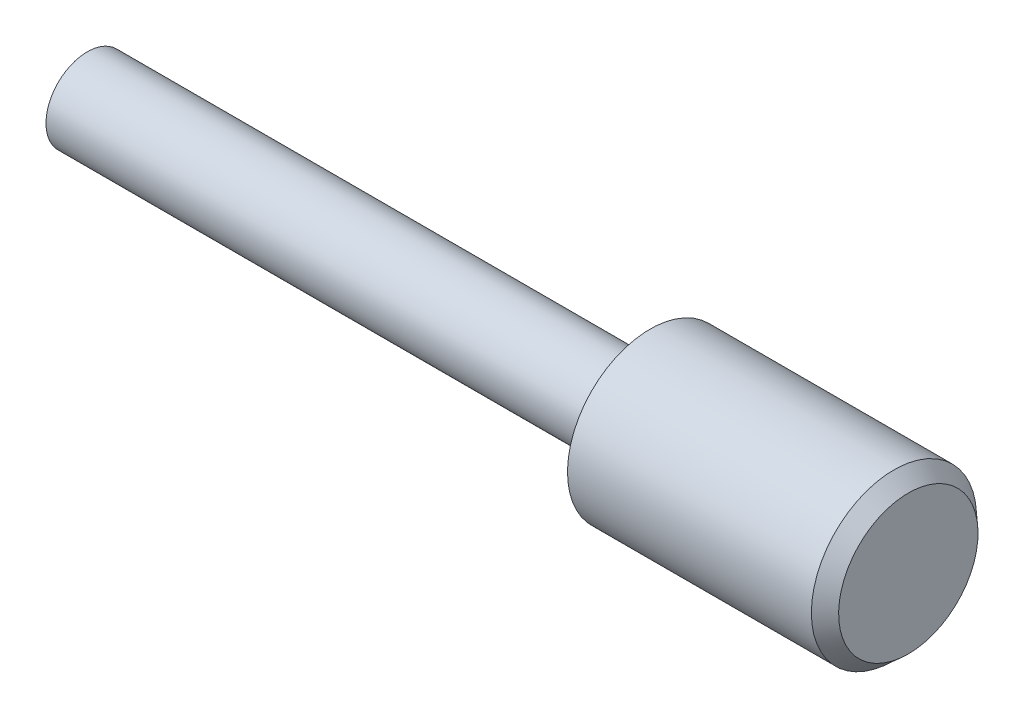
from build123d import *

# Parameters (mm, degrees)
PAH1_SIZE  = 5
PAH1_SIZE2 = 5.553062574


with BuildPart() as part:
    # Çizim1 → Döndür1 (revolve)
    with BuildSketch(Plane.XY):
        Polygon((-218, -32), (100, -32), (100, 0), (0, 0), (0, -16), (-218, -16), align=None)
    revolve(axis=Axis((-218, -32, 0), (1, 0, 0)))

    # Pah1
    pah1_edges = [part.edges().sort_by_distance(p)[0] for p in [
        (100, -64, 0),
    ]]
    pah1_side = [part.faces().sort_by_distance(p)[0] for p in [
        (100, -32, 0),
    ]]
    chamfer(pah1_edges, length=PAH1_SIZE, length2=PAH1_SIZE2, reference=pah1_side[0])


solid = part.part
